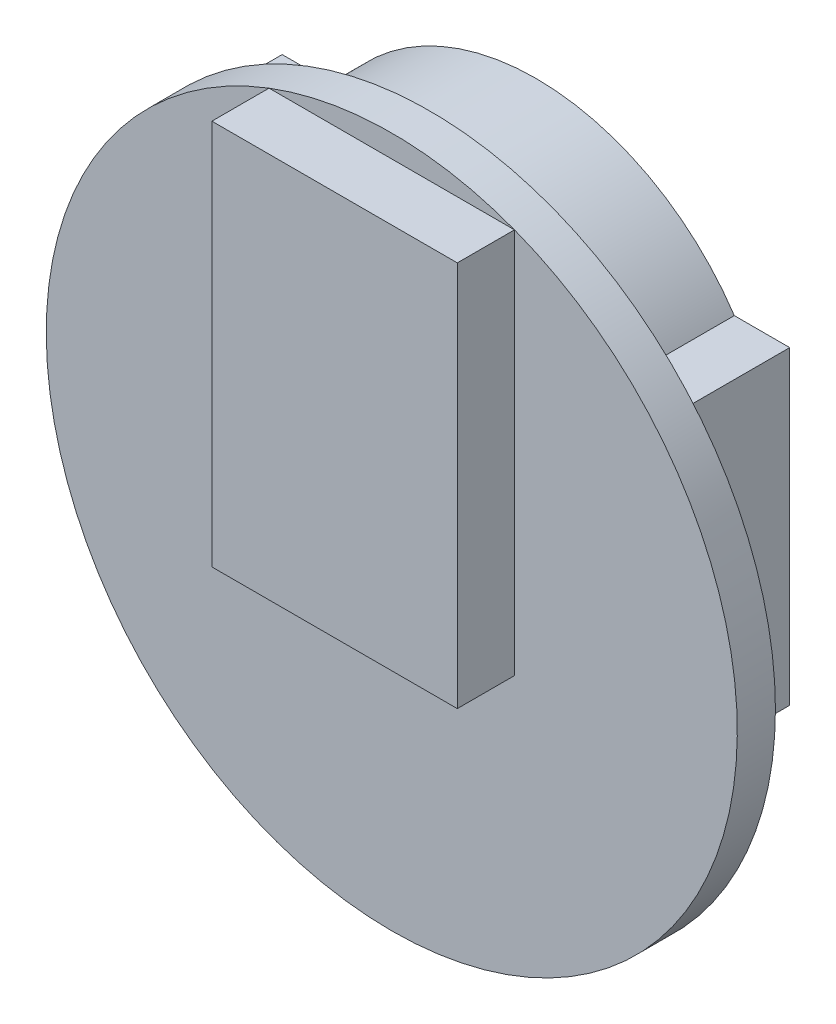
from build123d import *

# Parameters (mm, degrees)
ESQUISSE1_R        = 14.5
BOSS_EXTRU_1_DEPTH = 1.6
ESQUISSE2_W        = 10.3
ESQUISSE2_H        = 16.2
BOSS_EXTRU_2_DEPTH = 2.4
BOSS_EXTRU_3_DEPTH = 4.45
ESQUISSE4_W        = 6
ESQUISSE4_H        = 4
BOSS_EXTRU_4_DEPTH = 5.2
ESQUISSE5_W        = 3
ESQUISSE5_H        = 1.3
BOSS_EXTRU_5_DEPTH = 1.6


with BuildPart() as part:
    # Esquisse1 → Boss.-Extru.1 (new body)
    with BuildSketch(Plane.XY):
        with Locations((-3.708152602, 4.763148131)):
            Circle(ESQUISSE1_R)
    extrude(amount=BOSS_EXTRU_1_DEPTH)

    # Esquisse2 → Boss.-Extru.2 (add)
    with BuildSketch(Plane.XY.offset(1.6)):
        with Locations((-3.708152602, 10.217759892)):
            Rectangle(ESQUISSE2_W, ESQUISSE2_H)
    extrude(amount=BOSS_EXTRU_2_DEPTH)

    # Esquisse3 → Boss.-Extru.3 (add)
    with BuildSketch(Plane(origin=(0, 0, 0), x_dir=(-1, 0, 0), z_dir=(0, 0, -1))):
        with BuildLine():
            Line((7.708152602, -4.236851869), (14.358152602, 0.763148131))
            Line((14.358152602, 0.763148131), (14.358152602, 13.763148131))
            Line((14.358152602, 13.763148131), (12.033404554, 13.763148131))
            ThreePointArc((12.033404554, 13.763148131), (3.708152602, 18.223276297), (-4.617099351, 13.763148131))
            Line((-4.617099351, 13.763148131), (-6.941847398, 13.763148131))
            Line((-6.941847398, 13.763148131), (-6.941847398, 0.763148131))
            Line((-6.941847398, 0.763148131), (-0.291847398, -4.236851869))
            Line((-0.291847398, -4.236851869), (7.708152602, -4.236851869))
        make_face()
    extrude(amount=BOSS_EXTRU_3_DEPTH)

    # Esquisse4 → Boss.-Extru.4 (add)
    with BuildSketch(Plane(origin=(0, 0, 0), x_dir=(-1, 0, 0), z_dir=(0, 0, -1))):
        with Locations((3.708152602, -6.236851869)):
            Rectangle(ESQUISSE4_W, ESQUISSE4_H)
    extrude(amount=BOSS_EXTRU_4_DEPTH)

    # Esquisse5 → Boss.-Extru.5 (add)
    with BuildSketch(Plane(origin=(0, 0, -5.2), x_dir=(-1, 0, 0), z_dir=(0, 0, -1))):
        with Locations((3.708152602, -6.236851869)):
            Rectangle(ESQUISSE5_W, ESQUISSE5_H)
    extrude(amount=BOSS_EXTRU_5_DEPTH)


solid = part.part
